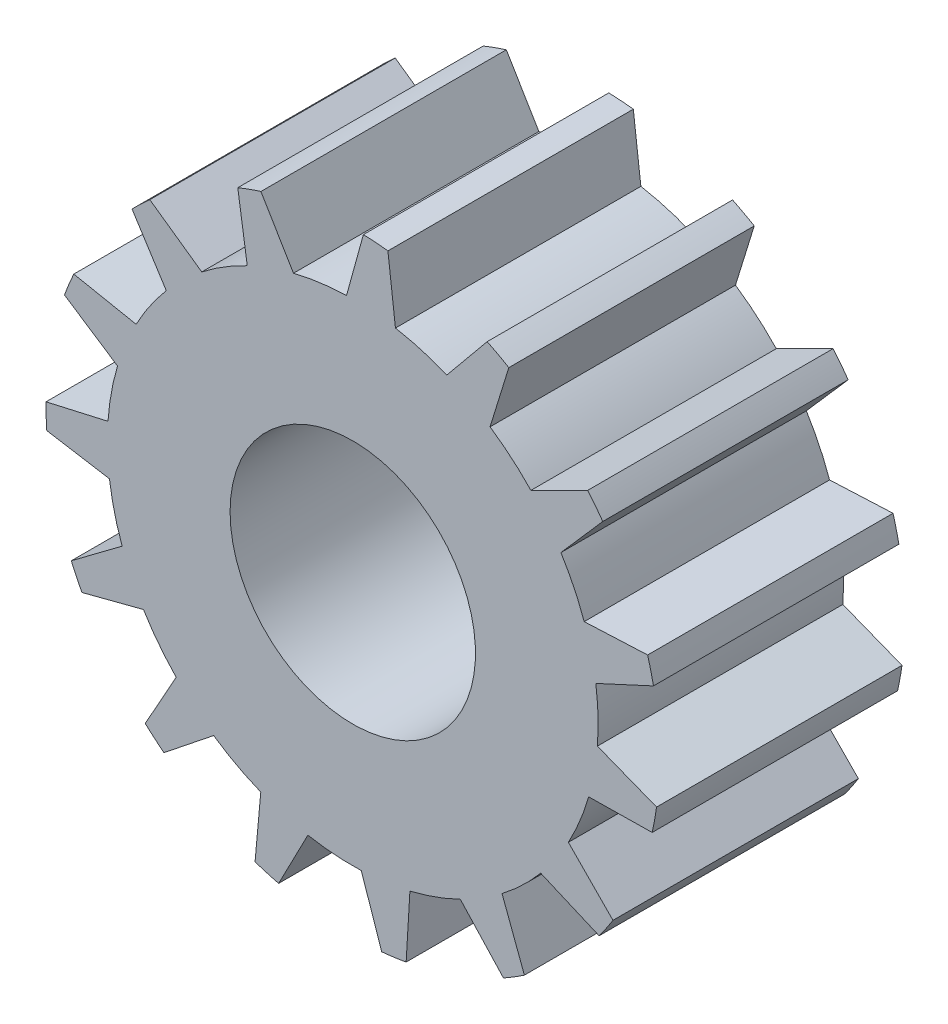
from build123d import *

# Parameters (mm, degrees)
SKETCH1_R           = 10
SKETCH1_R_2         = 5
BOSS_EXTRUDE1_DEPTH = 10
SKETCH2_R           = 12.5
BOSS_EXTRUDE2_DEPTH = 10
SKETCH3_R           = 5
CUT_EXTRUDE1_DEPTH  = 10
CUT_EXTRUDE4_DEPTH  = 10


with BuildPart() as part:
    # Sketch1 → Boss-Extrude1 (new body)
    with BuildSketch(Plane.XY):
        Circle(SKETCH1_R)
        Circle(SKETCH1_R_2, mode=Mode.SUBTRACT)
    extrude(amount=BOSS_EXTRUDE1_DEPTH)

    # Sketch2 → Boss-Extrude2 (add)
    with BuildSketch(Plane(origin=(0, 0, 0), x_dir=(-1, 0, 0), z_dir=(0, 0, -1))):
        Circle(SKETCH2_R)
    extrude(amount=-BOSS_EXTRUDE2_DEPTH)

    # Sketch3 → Cut-Extrude1 (cut)
    with BuildSketch(Plane(origin=(0, 0, 0), x_dir=(-1, 0, 0), z_dir=(0, 0, -1))):
        Circle(SKETCH3_R)
    extrude(amount=-CUT_EXTRUDE1_DEPTH, mode=Mode.SUBTRACT)

    # Sketch4 → Cut-Extrude4 (cut)
    with BuildSketch(Plane(origin=(0, 0, 0), x_dir=(-1, 0, 0), z_dir=(0, 0, -1))):
        with BuildLine():
            Line((-9.669699641, 8.08598777), (-7.258106214, 6.878945717))
            ThreePointArc((-7.258106214, 6.878945717), (-6.46463523, 7.629448954), (-5.59405076, 8.288944209))
            Line((-5.59405076, 8.288944209), (-6.390582917, 10.864931631))
            ThreePointArc((-6.390582917, 10.864931631), (-8.149466314, 9.616261652), (-9.669699641, 8.08598777))
        make_face()
        with BuildLine():
            Line((-5.544842662, 11.31993857), (-3.832690674, 9.23636737))
            ThreePointArc((-3.832690674, 9.23636737), (-2.802561694, 9.599252468), (-1.73900232, 9.847632758))
            Line((-1.73900232, 9.847632758), (-1.418922177, 12.524893183))
            ThreePointArc((-1.418922177, 12.524893183), (-3.53362195, 12.099578724), (-5.544842662, 11.31993857))
        make_face()
        with BuildLine():
            Line((-0.461232014, 12.596569152), (0.255431902, 9.996737195))
            ThreePointArc((0.255431902, 9.996737195), (1.34410022, 9.909258025), (2.41673542, 9.70357614))
            Line((2.41673542, 9.70357614), (3.798083099, 12.019186917))
            ThreePointArc((3.798083099, 12.019186917), (1.693217751, 12.490768712), (-0.461232014, 12.596569152))
        make_face()
        with BuildLine():
            Line((4.70212984, 11.695138492), (4.299387983, 9.028580341))
            ThreePointArc((4.299387983, 9.028580341), (5.258354995, 8.505862846), (6.15459765, 7.881683054))
            Line((6.15459765, 7.881683054), (8.358365302, 9.435254043))
            ThreePointArc((8.358365302, 9.435254043), (6.627284721, 10.722191316), (4.70212984, 11.695138492))
        make_face()
        with BuildLine():
            Line((9.052450727, 8.771512139), (7.599940822, 6.499299924))
            ThreePointArc((7.599940822, 6.499299924), (8.26339242, 5.631726707), (8.828274034, 4.696975365))
            Line((8.828274034, 4.696975365), (11.473410211, 5.219880028))
            ThreePointArc((11.473410211, 5.219880028), (10.415433955, 7.099649632), (9.052450727, 8.771512139))
        make_face()
        with BuildLine():
            Line((11.837520645, 4.331211651), (9.58639485, 2.846231506))
            ThreePointArc((9.58639485, 2.846231506), (9.839614226, 1.783813859), (9.975461635, 0.700117964))
            Line((9.975461635, 0.700117964), (12.604598262, 0.101941336))
            ThreePointArc((12.604598262, 0.101941336), (12.402660038, 2.249514029), (11.837520645, 4.331211651))
        make_face()
        with BuildLine():
            Line((12.575775702, -0.857994679), (9.915274118, -1.298976196))
            ThreePointArc((9.915274118, -1.298976196), (9.714477342, -2.372536612), (9.397801295, -3.417796193))
            Line((9.397801295, -3.417796193), (11.556336764, -5.03362394))
            ThreePointArc((11.556336764, -5.03362394), (12.245353525, -2.989582985), (12.575775702, -0.857994679))
        make_face()
        with BuildLine():
            Line((11.139564893, -5.898845935), (8.529712414, -5.219579114))
            ThreePointArc((8.529712414, -5.219579114), (7.909619072, -6.118653948), (7.195175735, -6.944742338))
            Line((7.195175735, -6.944742338), (8.509879654, -9.298829908))
            ThreePointArc((8.509879654, -9.298829908), (9.970714142, -7.711753943), (11.139564893, -5.898845935))
        make_face()
        with BuildLine():
            Line((7.777222115, -9.919733139), (5.669285944, -8.237669384))
            ThreePointArc((5.669285944, -8.237669384), (4.737115808, -8.80680043), (3.748438924, -9.270879442))
            Line((3.748438924, -9.270879442), (3.991987042, -11.956183707))
            ThreePointArc((3.991987042, -11.956183707), (5.972047703, -11.100492584), (7.777222115, -9.919733139))
        make_face()
        with BuildLine():
            Line((3.070126979, -12.225408366), (1.82858843, -9.831391781))
            ThreePointArc((1.82858843, -9.831391781), (0.745522186, -9.972171111), (-0.34643703, -9.993997268))
            Line((-0.34643703, -9.993997268), (-1.216156396, -12.546204725))
            ThreePointArc((-1.216156396, -12.546204725), (0.940759962, -12.569855213), (3.070126979, -12.225408366))
        make_face()
        with BuildLine():
            Line((-2.167821003, -12.417199422), (-2.328288635, -9.725177224))
            ThreePointArc((-2.328288635, -9.725177224), (-3.374978996, -9.413262813), (-4.381410875, -8.989062173))
            Line((-4.381410875, -8.989062173), (-6.214015345, -10.966872967))
            ThreePointArc((-6.214015345, -10.966872967), (-4.253193723, -11.865775682), (-2.167821003, -12.417199422))
        make_face()
        with BuildLine():
            Line((-7.03093304, -10.461943891), (-6.082583444, -7.937391174))
            ThreePointArc((-6.082583444, -7.937391174), (-6.911915648, -7.226715857), (-7.658798975, -6.429836565))
            Line((-7.658798975, -6.429836565), (-10.137414587, -7.491269242))
            ThreePointArc((-10.137414587, -7.491269242), (-8.711731575, -9.109995738), (-7.03093304, -10.461943891))
        make_face()
        with BuildLine():
            Line((-10.678332879, -6.697723217), (-8.785144317, -4.777158081))
            ThreePointArc((-8.785144317, -4.777158081), (-9.253719292, -3.790604077), (-9.611911155, -2.758833802))
            Line((-9.611911155, -2.758833802), (-12.307962753, -2.72035701))
            ThreePointArc((-12.307962753, -2.72035701), (-11.663931893, -4.77901477), (-10.678332879, -6.697723217))
        make_face()
        with BuildLine():
            Line((-12.479351955, -1.775405353), (-9.968673927, -0.790910957))
            ThreePointArc((-9.968673927, -0.790910957), (-9.995470803, 0.300937585), (-9.903036574, 1.389196388))
            Line((-9.903036574, 1.389196388), (-12.350352343, 2.520929664))
            ThreePointArc((-12.350352343, 2.520929664), (-12.599332424, 0.378301268), (-12.479351955, -1.775405353))
        make_face()
        with BuildLine():
            Line((-12.122577706, 3.453896227), (-9.428529252, 3.332091857))
            ThreePointArc((-9.428529252, 3.332091857), (-9.008914606, 4.340444404), (-8.481837004, 5.297021903))
            Line((-8.481837004, 5.297021903), (-10.257253815, 7.326324696))
            ThreePointArc((-10.257253815, 7.326324696), (-11.356193917, 5.47020558), (-12.122577706, 3.453896227))
        make_face()
    extrude(amount=-CUT_EXTRUDE4_DEPTH, mode=Mode.SUBTRACT)


solid = part.part
